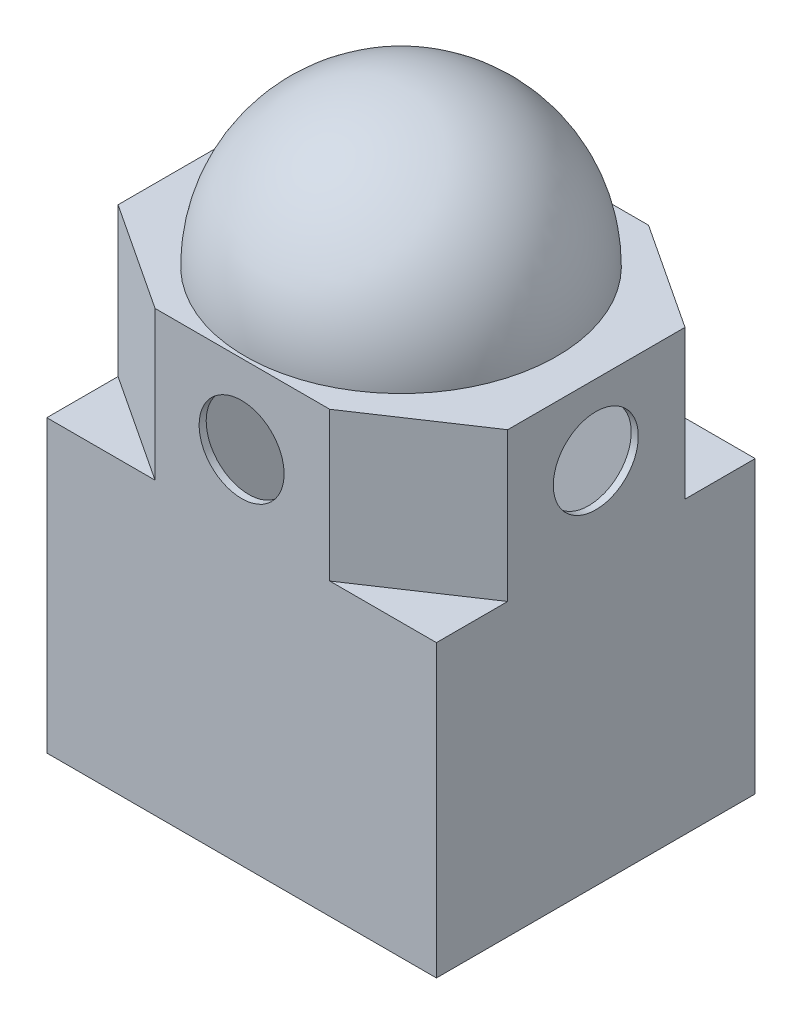
from build123d import *

# Parameters (mm, degrees)
SKETCH1_W           = 110
SKETCH1_H           = 90
SKETCH1_W_2         = 106
SKETCH1_H_2         = 86
BOSS_EXTRUDE1_DEPTH = 80
SKETCH2_W           = 110
SKETCH2_H           = 90
BOSS_EXTRUDE2_DEPTH = 2
BOSS_EXTRUDE3_DEPTH = 40
CUT_EXTRUDE1_DEPTH  = 40
BOSS_EXTRUDE4_DEPTH = 2
SKETCH11_W          = 23
SKETCH11_H          = 13
CUT_EXTRUDE2_DEPTH  = 13
REVOLVE_THIN3_ANGLE = 180
SKETCH13_R          = 12
CUT_EXTRUDE3_DEPTH  = 97
SKETCH14_R          = 12
CUT_EXTRUDE4_DEPTH  = 112


with BuildPart() as part:
    # Sketch1 → Boss-Extrude1 (new body)
    with BuildSketch(Plane(origin=(0, 0, 0), x_dir=(1, 0, 0), z_dir=(0, 1, 0))):
        Rectangle(SKETCH1_W, SKETCH1_H)
        Rectangle(SKETCH1_W_2, SKETCH1_H_2, mode=Mode.SUBTRACT)
    extrude(amount=BOSS_EXTRUDE1_DEPTH)

    # Sketch2 → Boss-Extrude2 (add)
    with BuildSketch(Plane(origin=(0, 80, 0), x_dir=(1, 0, 0), z_dir=(0, 1, 0))):
        Rectangle(SKETCH2_W, SKETCH2_H)
    extrude(amount=BOSS_EXTRUDE2_DEPTH)

    # Sketch3 → Boss-Extrude3 (add)
    with BuildSketch(Plane(origin=(0, 82, 0), x_dir=(1, 0, 0), z_dir=(0, 1, 0))):
        Polygon((55, 25.177973791), (24.883494565, 45), (-25.030734178, 45), (-55, 25.177973791), (-55, -24.883494565), (-24.436078892, -45), (24.883494565, -45), (55, -24.883494565), align=None)
        Polygon((53, 24.100004746), (24.284378107, 43), (-24.429161834, 43), (-53, 24.102910351), (-53, -23.805525521), (-23.836962434, -43), (24.27696917, -43), (53, -23.814274516), align=None, mode=Mode.SUBTRACT)
    extrude(amount=BOSS_EXTRUDE3_DEPTH)

    # Sketch7 → Cut-Extrude1 (cut)
    with BuildSketch(Plane(origin=(0, 82, 0), x_dir=(1, 0, 0), z_dir=(0, 1, 0))):
        Polygon((-24.429161834, 43), (-53, 24.102910351), (-53, -23.805525521), (-23.836962434, -43), (24.27696917, -43), (53, -23.814274516), (53, 24.100004746), (24.284378107, 43), align=None)
    extrude(amount=-CUT_EXTRUDE1_DEPTH, mode=Mode.SUBTRACT)

    # Sketch8 → Boss-Extrude4 (add)
    with BuildSketch(Plane(origin=(0, 122, 0), x_dir=(1, 0, 0), z_dir=(0, 1, 0))):
        Polygon((24.883494565, 45), (55, 25.177973791), (55, -24.883494565), (24.883494565, -45), (-24.436078892, -45), (-55, -24.883494565), (-55, 25.177973791), (-25.030734178, 45), align=None)
    extrude(amount=BOSS_EXTRUDE4_DEPTH)

    # Sketch11 → Cut-Extrude2 (cut)
    with BuildSketch(Plane(origin=(0, 124, 0), x_dir=(1, 0, 0), z_dir=(0, 1, 0))):
        Rectangle(SKETCH11_W, SKETCH11_H)
    extrude(amount=-CUT_EXTRUDE2_DEPTH, mode=Mode.SUBTRACT)

    # Sketch12 → Revolve-Thin3 (revolve)
    with BuildSketch(Plane(origin=(0, 124, 0), x_dir=(1, 0, 0), z_dir=(0, 1, 0))):
        with BuildLine():
            ThreePointArc((-43.995827048, 0), (0, -43.995827048), (43.995827048, 0))
            Line((43.995827048, 0), (41.995827048, 0))
            ThreePointArc((41.995827048, 0), (0, -41.995827048), (-41.995827048, 0))
            Line((-41.995827048, 0), (-43.995827048, 0))
        make_face()
    revolve(axis=Axis((43.995827048, 124, 0), (-1, 0, 0)), revolution_arc=REVOLVE_THIN3_ANGLE)

    # Sketch13 → Cut-Extrude3 (cut)
    with BuildSketch(Plane(origin=(0, 0, -45), x_dir=(-1, 0, 0), z_dir=(0, 0, -1))):
        with Locations((0, 101.721715456)):
            Circle(SKETCH13_R)
    extrude(amount=-CUT_EXTRUDE3_DEPTH, mode=Mode.SUBTRACT)

    # Sketch14 → Cut-Extrude4 (cut)
    with BuildSketch(Plane.ZY.offset(55)):
        with Locations((0, 103.980631389)):
            Circle(SKETCH14_R)
    extrude(amount=-CUT_EXTRUDE4_DEPTH, mode=Mode.SUBTRACT)


solid = part.part
